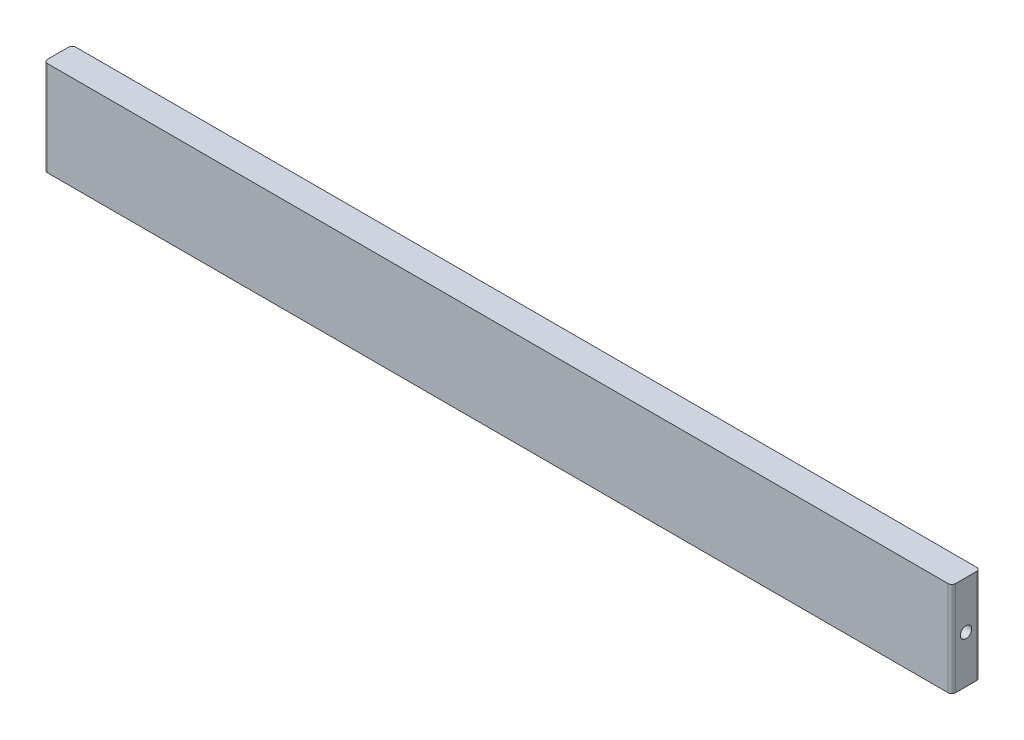
from build123d import *

# Parameters (mm, degrees)
SKETCH1_W                  = 304.8
SKETCH1_H                  = 9.525
BOSS_EXTRUDE1_DEPTH        = 31.75
F_10_24_TAPPED_HOLE1_D     = 3.7973
F_10_24_TAPPED_HOLE1_DEPTH = 19.05
F_10_24_TAPPED_HOLE1_TIP   = 1.140824014
FILLET1_R                  = 1.27


with BuildPart() as part:
    # Sketch1 → Boss-Extrude1 (new body)
    with BuildSketch(Plane(origin=(0, -21, 0), x_dir=(1, 0, 0), z_dir=(0, 1, 0))):
        with Locations((6.69e-07, -174.7625)):
            Rectangle(SKETCH1_W, SKETCH1_H)
    extrude(amount=BOSS_EXTRUDE1_DEPTH)

    # #10-24 Tapped Hole1
    with Locations(Plane(origin=(0, -21, 0), x_dir=(-1, 0, 0), z_dir=(0, -1, 0))):
        with Locations((-127.000000669, -174.7625), (-42.333334002, -174.7625), (126.999999331, -174.7625), (42.333332664, -174.7625)):
            Hole(F_10_24_TAPPED_HOLE1_D / 2, depth=F_10_24_TAPPED_HOLE1_DEPTH)
            with Locations((0, 0, -(F_10_24_TAPPED_HOLE1_DEPTH + F_10_24_TAPPED_HOLE1_TIP / 2))):  # 118° drill point
                Cone(0, F_10_24_TAPPED_HOLE1_D / 2, F_10_24_TAPPED_HOLE1_TIP, mode=Mode.SUBTRACT)

    # Sketch5 → #10-24 Tapped Hole2 (revolve, cut)
    with BuildSketch(Plane(origin=(152.400000669, -5.125, 174.7625), x_dir=(0, 0, -1), z_dir=(0, 1, 0))):
        Polygon((0, 0), (0, 20.190824014), (1.89865, 19.05), (1.89865, 0), align=None)
    f_10_24_tapped_hole2 = revolve(axis=Axis((158.750000669, -5.125, 174.7625), (-1, 0, 0)), mode=Mode.SUBTRACT)

    # Mirror1: #10-24 Tapped Hole2 across plane
    add(f_10_24_tapped_hole2.mirror(Plane(origin=(0, 0, 0), x_dir=(0, 0, 1), z_dir=(1, 0, 0))), mode=Mode.SUBTRACT)

    # Fillet1
    fillet1_edges = [part.edges().sort_by_distance(p)[0] for p in [
        (152.400000669, -5.125, 170),
        (152.400000669, -5.125, 179.525),
        (-152.399999331, -5.125, 179.525),
        (-152.399999331, -5.125, 170),
    ]]
    fillet(fillet1_edges, radius=FILLET1_R)


solid = part.part
